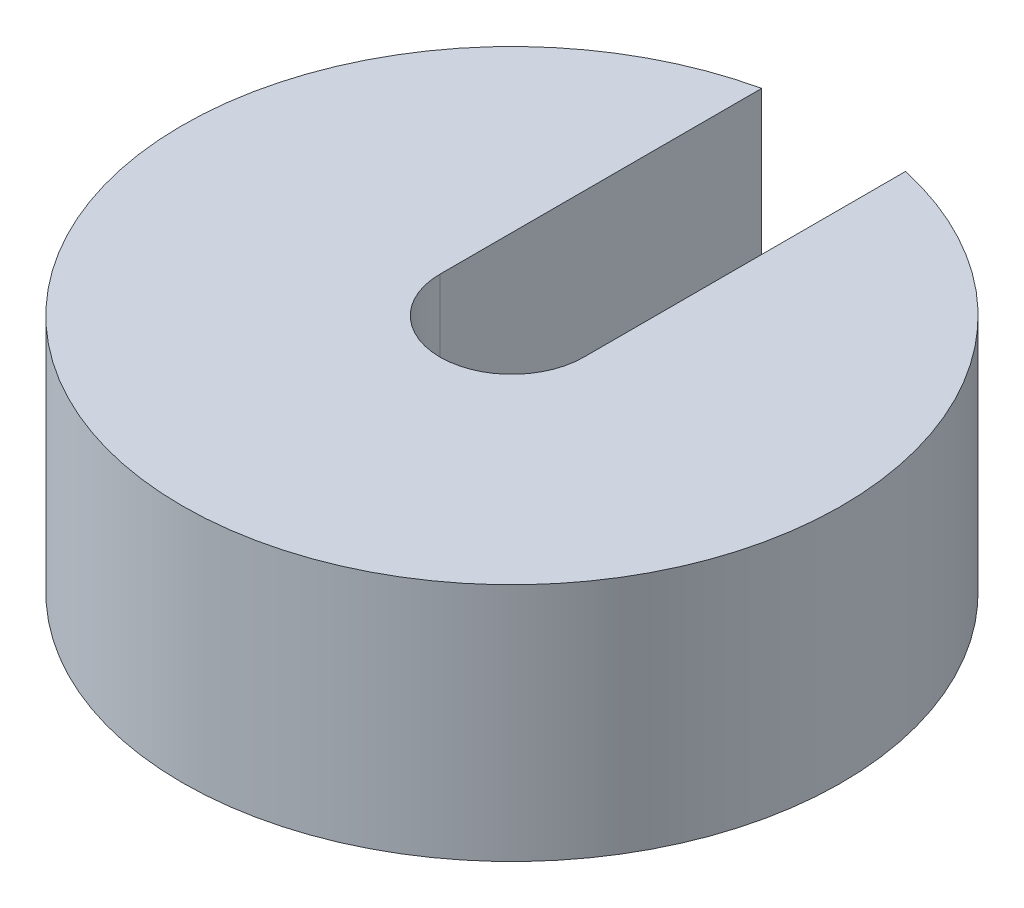
from build123d import *

# Parameters (mm, degrees)
BOSS_EXTRUDE1_DEPTH = 20


with BuildPart() as part:
    # Sketch2 → Boss-Extrude1 (new body)
    with BuildSketch(Plane(origin=(0, 0, 0), x_dir=(1, 0, 0), z_dir=(0, 1, 0))):
        with BuildLine():
            ThreePointArc((6, 0), (0, -6), (-6, 0))
            Line((-6, 0), (-6, 26.837473801))
            ThreePointArc((-6, 26.837473801), (-17.193748864, -21.462176031), (27.5, 0))
            ThreePointArc((27.5, 0), (21.462176031, 17.193748864), (6, 26.837473801))
            Line((6, 26.837473801), (6, 0))
        make_face()
    extrude(amount=BOSS_EXTRUDE1_DEPTH)


solid = part.part
